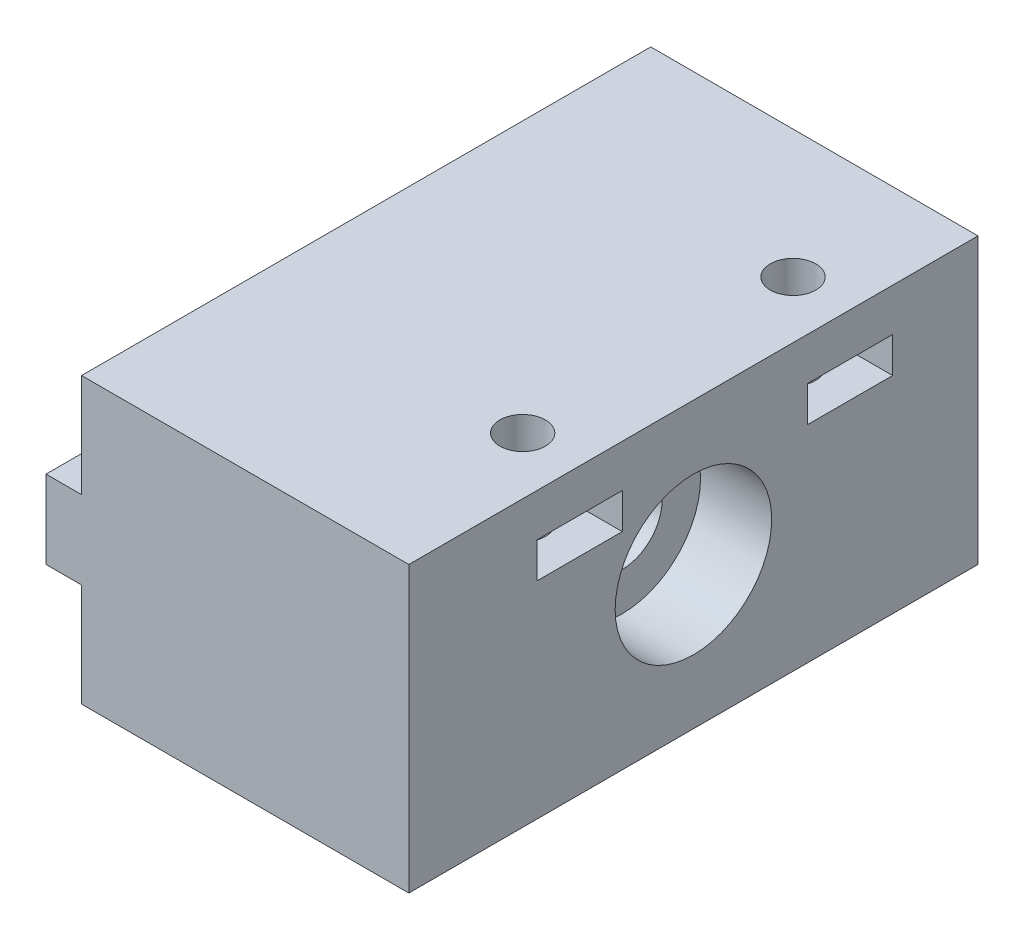
from build123d import *

# Parameters (mm, degrees)
SKETCH1_W           = 23
SKETCH1_H           = 40
BOSS_EXTRUDE1_DEPTH = 20
SKETCH5_R           = 1.6
CUT_EXTRUDE3_DEPTH  = 21
SKETCH6_W           = 6
SKETCH6_H           = 2.5
CUT_EXTRUDE4_DEPTH  = 8
SKETCH7_R           = 2.8
CUT_EXTRUDE5_DEPTH  = 24
SKETCH8_R           = 5.5
CUT_EXTRUDE6_DEPTH  = 5
SKETCH9_W           = 13
SKETCH9_H           = 5.5
BOSS_EXTRUDE6_DEPTH = 2.5


with BuildPart() as part:
    # Sketch1 → Boss-Extrude1 (new body)
    with BuildSketch(Plane(origin=(0, 0, 0), x_dir=(1, 0, 0), z_dir=(0, 1, 0))):
        with Locations((10.80324178, 20)):
            Rectangle(SKETCH1_W, SKETCH1_H)
    extrude(amount=BOSS_EXTRUDE1_DEPTH)

    # Sketch5 → Cut-Extrude3 (cut, through all)
    with BuildSketch(Plane(origin=(0, 20, 0), x_dir=(1, 0, 0), z_dir=(0, 1, 0))):
        with Locations((18.30324178, 12)):
            Circle(SKETCH5_R)
        with Locations((18.30324178, 31)):
            Circle(SKETCH5_R)
    extrude(amount=-CUT_EXTRUDE3_DEPTH, mode=Mode.SUBTRACT)

    # Sketch6 → Cut-Extrude4 (cut)
    with BuildSketch(Plane(origin=(22.30324178, 0, 0), x_dir=(0, 0, -1), z_dir=(1, 0, 0))):
        with Locations((12, 15.75)):
            Rectangle(SKETCH6_W, SKETCH6_H)
        with Locations((31, 15.75)):
            Rectangle(SKETCH6_W, SKETCH6_H)
    extrude(amount=-CUT_EXTRUDE4_DEPTH, mode=Mode.SUBTRACT)

    # Sketch7 → Cut-Extrude5 (cut, through all)
    with BuildSketch(Plane.ZY.offset(0.69675822)):
        with Locations((-20, 10)):
            Circle(SKETCH7_R)
    extrude(amount=-CUT_EXTRUDE5_DEPTH, mode=Mode.SUBTRACT)

    # Sketch8 → Cut-Extrude6 (cut)
    with BuildSketch(Plane(origin=(22.30324178, 0, 0), x_dir=(0, 0, -1), z_dir=(1, 0, 0))):
        with Locations((20, 10)):
            Circle(SKETCH8_R)
    extrude(amount=-CUT_EXTRUDE6_DEPTH, mode=Mode.SUBTRACT)

    # Sketch9 → Boss-Extrude6 (add)
    with BuildSketch(Plane.ZY.offset(0.69675822)):
        with Locations((-33.5, 10)):
            Rectangle(SKETCH9_W, SKETCH9_H)
        with Locations((-6.5, 10)):
            Rectangle(SKETCH9_W, SKETCH9_H)
    extrude(amount=BOSS_EXTRUDE6_DEPTH)


solid = part.part
